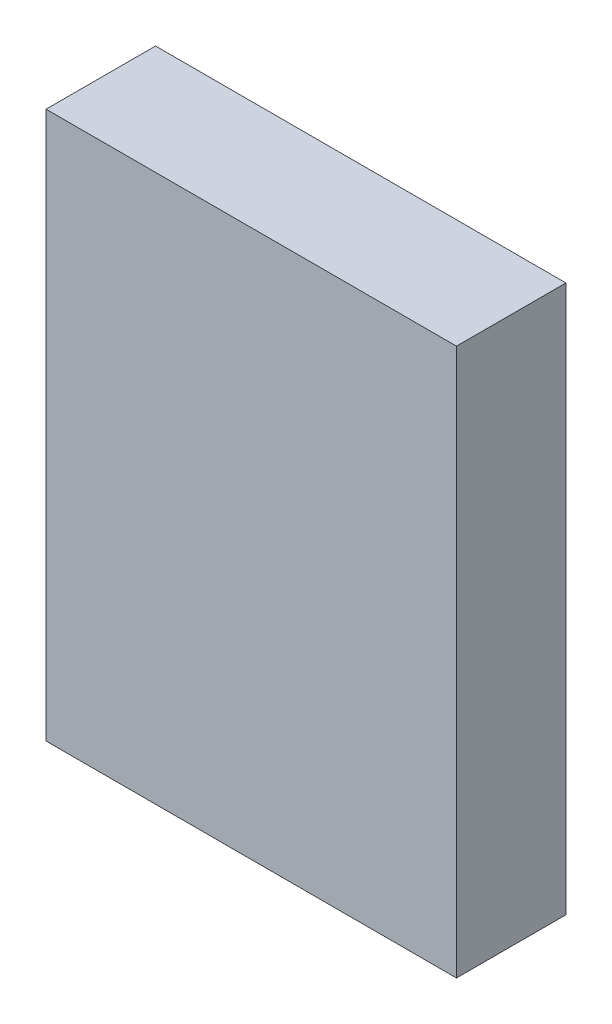
from build123d import *

# Parameters (mm, degrees)
ESBO_O1_W                = 22.5
ESBO_O1_H                = 30
RESSALTO_EXTRUS_O1_DEPTH = 6


with BuildPart() as part:
    # Esboço1 → Ressalto-extrusão1 (new body)
    with BuildSketch(Plane.XY):
        with Locations((11.25, 15)):
            Rectangle(ESBO_O1_W, ESBO_O1_H)
    extrude(amount=RESSALTO_EXTRUS_O1_DEPTH)


solid = part.part
